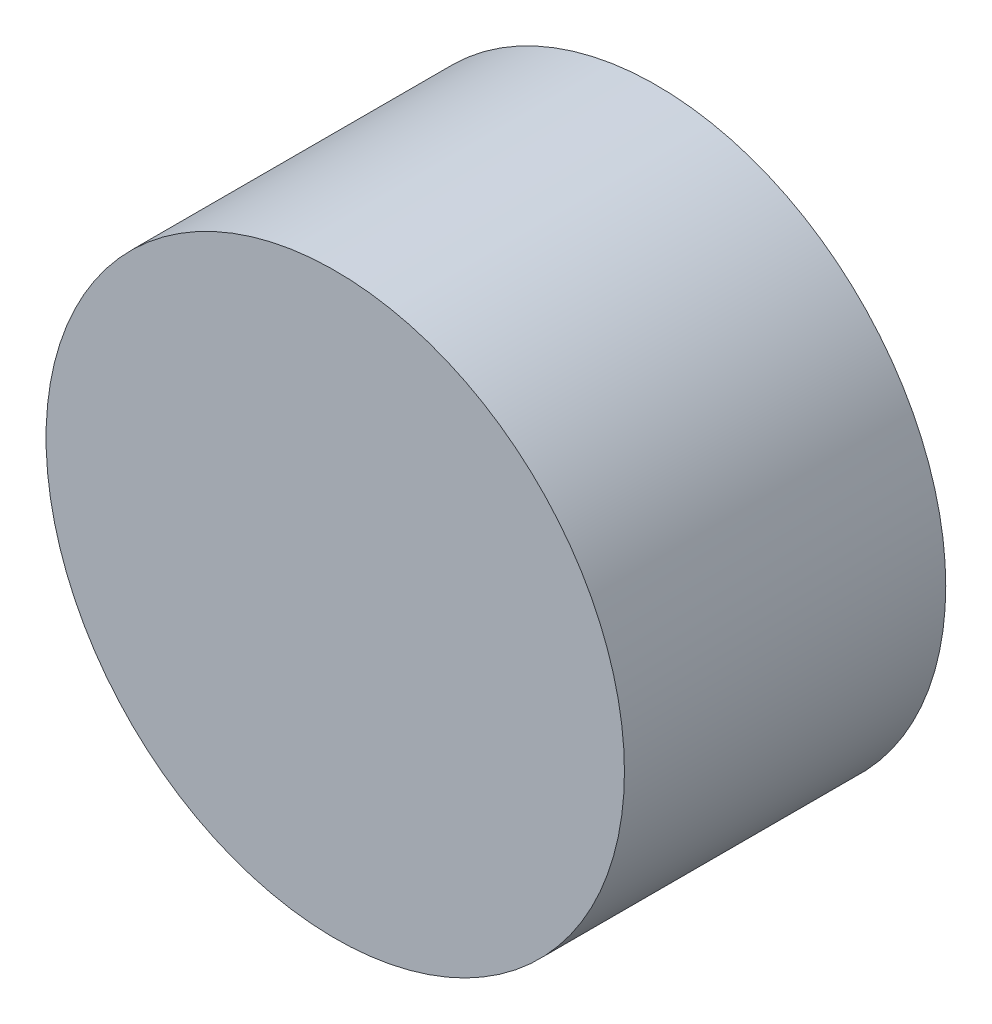
from build123d import *

# Parameters (mm, degrees)
SKETCH1_R           = 9
BOSS_EXTRUDE1_DEPTH = 10
SKETCH2_R           = 3
CUT_EXTRUDE1_DEPTH  = 8


with BuildPart() as part:
    # Sketch1 → Boss-Extrude1 (new body)
    with BuildSketch(Plane.XY):
        Circle(SKETCH1_R)
    extrude(amount=BOSS_EXTRUDE1_DEPTH)

    # Sketch2 → Cut-Extrude1 (cut)
    with BuildSketch(Plane(origin=(0, 0, 0), x_dir=(-1, 0, 0), z_dir=(0, 0, -1))):
        Circle(SKETCH2_R)
    extrude(amount=-CUT_EXTRUDE1_DEPTH, mode=Mode.SUBTRACT)


solid = part.part
